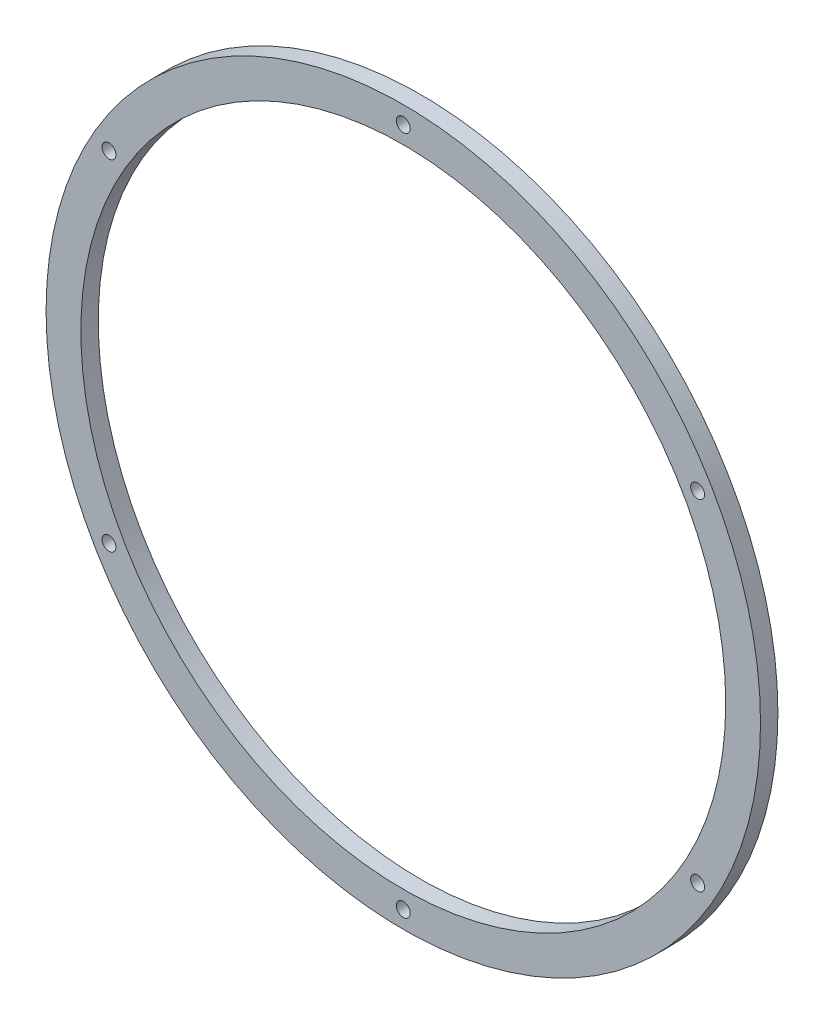
from build123d import *

# Parameters (mm, degrees)
SKETCH1_R          = 205.4
SKETCH1_R_2        = 185.4
BODY_DEPTH         = 5
SKETCH2_R          = 4
CUT_EXTRUDE1_DEPTH = 11
HOLES_COUNT        = 6


with BuildPart() as part:
    # Sketch1 → Body (new body, symmetric)
    with BuildSketch(Plane.XY):
        Circle(SKETCH1_R)
        Circle(SKETCH1_R_2, mode=Mode.SUBTRACT)
    extrude(amount=BODY_DEPTH, both=True)

    # Sketch2 → Cut-Extrude1 (cut, through all)
    with BuildSketch(Plane.XY.offset(5)):
        with Locations((0, 195.4)):
            Circle(SKETCH2_R)
    cut_extrude1 = extrude(amount=-CUT_EXTRUDE1_DEPTH, mode=Mode.SUBTRACT)

    # Holes: Cut-Extrude1 ×6 about axis
    holes_axis = Axis((0, 0, 0), (0, 0, 1))
    for i in range(1, HOLES_COUNT):
        add(cut_extrude1.rotate(holes_axis, i * 360 / HOLES_COUNT), mode=Mode.SUBTRACT)


solid = part.part
